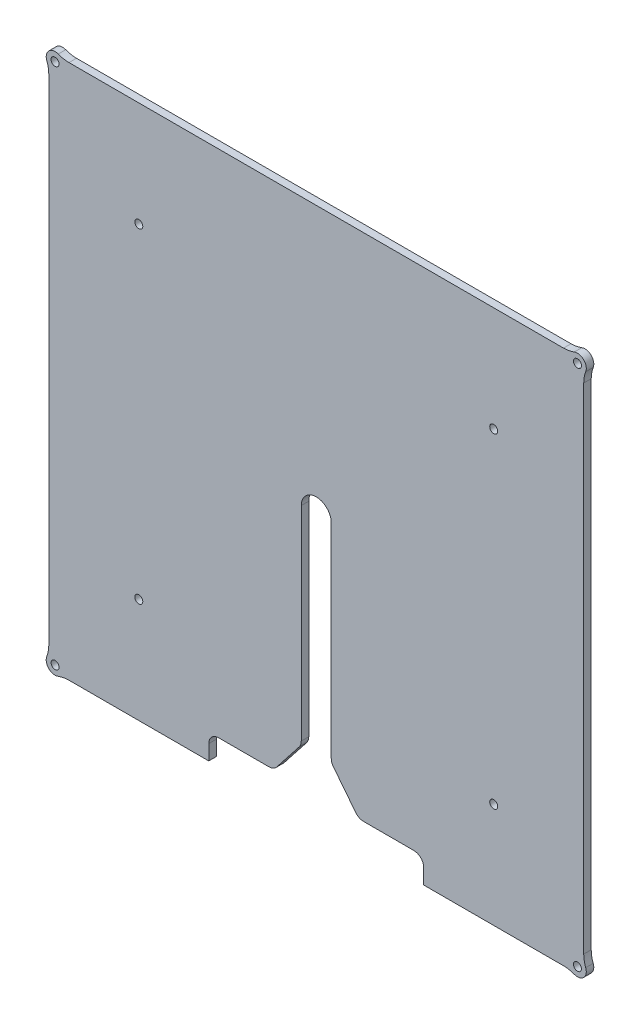
from build123d import *

# Parameters (mm, degrees)
SKETCH1_R           = 1.6
BOSS_EXTRUDE1_DEPTH = 3
CUT_EXTRUDE1_DEPTH  = 4
CUT_EXTRUDE3_DEPTH  = 4
FILLET1_R           = 4
SKETCH3_R           = 1.6
CUT_EXTRUDE2_DEPTH  = 4


with BuildPart() as part:
    # Sketch1 → Boss-Extrude1 (new body)
    with BuildSketch(Plane.XY):
        with BuildLine():
            Line((-107, 98.923010333), (-107, -98.923010333))
            ThreePointArc((-107, -98.923010333), (-107.201661971, -101.11372249), (-107.799869959, -103.230804092))
            ThreePointArc((-107.799869959, -103.230804092), (-107, -107), (-103.230804092, -107.799869959))
            ThreePointArc((-103.230804092, -107.799869959), (-101.11372249, -107.201661971), (-98.923010333, -107))
            Line((-98.923010333, -107), (-43, -107))
            Line((-43, -107), (-43, -101))
            ThreePointArc((-43, -101), (-41.828427125, -98.171572875), (-39, -97))
            Line((-39, -97), (39, -97))
            ThreePointArc((39, -97), (41.828427125, -98.171572875), (43, -101))
            Line((43, -101), (43, -107))
            Line((43, -107), (98.923010333, -107))
            ThreePointArc((98.923010333, -107), (101.11372249, -107.201661971), (103.230804092, -107.799869959))
            ThreePointArc((103.230804092, -107.799869959), (107, -107), (107.799869959, -103.230804092))
            ThreePointArc((107.799869959, -103.230804092), (107.201661971, -101.11372249), (107, -98.923010333))
            Line((107, -98.923010333), (107, 98.923010333))
            ThreePointArc((107, 98.923010333), (107.201661971, 101.11372249), (107.799869959, 103.230804092))
            ThreePointArc((107.799869959, 103.230804092), (107, 107), (103.230804092, 107.799869959))
            ThreePointArc((103.230804092, 107.799869959), (101.11372249, 107.201661971), (98.923010333, 107))
            Line((98.923010333, 107), (-98.923010333, 107))
            ThreePointArc((-98.923010333, 107), (-101.11372249, 107.201661971), (-103.230804092, 107.799869959))
            ThreePointArc((-103.230804092, 107.799869959), (-107, 107), (-107.799869959, 103.230804092))
            ThreePointArc((-107.799869959, 103.230804092), (-107.201661971, 101.11372249), (-107, 98.923010333))
        make_face()
        with Locations((-104.5, -104.5)):
            Circle(SKETCH1_R, mode=Mode.SUBTRACT)
        with Locations((-104.5, 104.5)):
            Circle(SKETCH1_R, mode=Mode.SUBTRACT)
        with Locations((104.5, 104.5)):
            Circle(SKETCH1_R, mode=Mode.SUBTRACT)
        with Locations((104.5, -104.5)):
            Circle(SKETCH1_R, mode=Mode.SUBTRACT)
    extrude(amount=BOSS_EXTRUDE1_DEPTH)

    # Sketch2 → Cut-Extrude1 (cut, through all)
    with BuildSketch(Plane(origin=(0, 0, 0), x_dir=(-1, 0, 0), z_dir=(0, 0, -1))):
        with BuildLine():
            Line((6, -97), (-6, -97))
            Line((-6, -97), (-6, 0))
            ThreePointArc((-6, 0), (0, 6), (6, 0))
            Line((6, 0), (6, -97))
        make_face()
    extrude(amount=-CUT_EXTRUDE1_DEPTH, mode=Mode.SUBTRACT)

    # Sketch4 → Cut-Extrude3 (cut, through all)
    with BuildSketch(Plane.XY.offset(3)):
        Polygon((-17, -97), (17, -97), (6, -83), (-6, -83), align=None)
    extrude(amount=-CUT_EXTRUDE3_DEPTH, mode=Mode.SUBTRACT)

    # Fillet1
    fillet1_edges = [part.edges().sort_by_distance(p)[0] for p in [
        (-17, -97, 1.5),
        (-6, -83, 1.5),
        (6, -83, 1.5),
        (17, -97, 1.5),
    ]]
    fillet(fillet1_edges, radius=FILLET1_R)

    # Sketch3 → Cut-Extrude2 (cut, through all)
    with BuildSketch(Plane.XY.offset(3)):
        with Locations((-71, 65)):
            Circle(SKETCH3_R)
        with Locations((71, 65)):
            Circle(SKETCH3_R)
        with Locations((71, -65)):
            Circle(SKETCH3_R)
        with Locations((-71, -65)):
            Circle(SKETCH3_R)
    extrude(amount=-CUT_EXTRUDE2_DEPTH, mode=Mode.SUBTRACT)


solid = part.part
